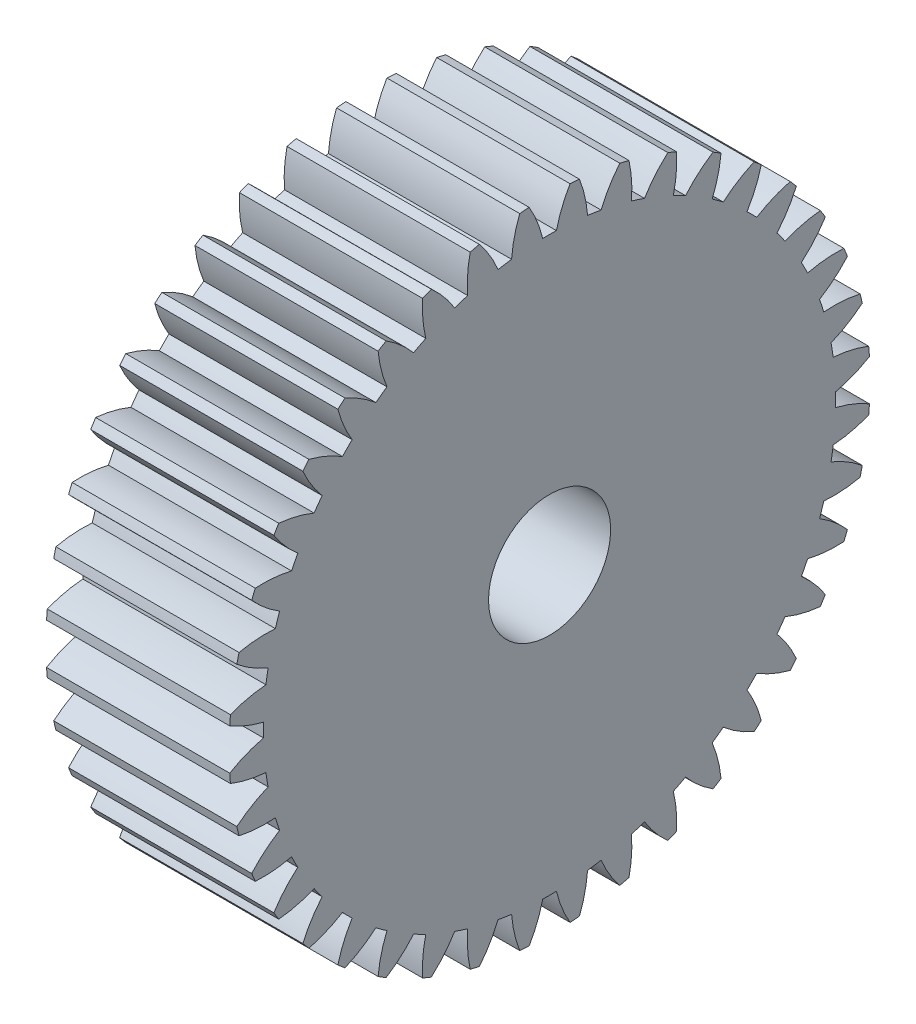
from build123d import *

# Parameters (mm, degrees)
BASPROSKE_W     = 12
BASPROSKE_H     = 21
TOOTHCUT_DEPTH  = 33.031234756
TEETHCUTS_COUNT = 40
TEETHCUTS_ANGLE = 351
BORSKE_R        = 4
BORE_DEPTH      = 50.0000508


with BuildPart() as part:
    # BasProSke → Base-Revolve (revolve)
    with BuildSketch(Plane(origin=(0, 0, 0), x_dir=(1, 0, 0), z_dir=(0, 1, 0)), mode=Mode.PRIVATE) as base_revolve_sk:
        with Locations((6, 10.5)):
            Rectangle(BASPROSKE_W, BASPROSKE_H)
    revolve(base_revolve_sk.sketch.rotate(Axis((-10, 0, 0), (1, 0, 0)), 180), axis=Axis((-10, 0, 0), (1, 0, 0)))

    # TooCutSke → ToothCut (cut, through all)
    with BuildSketch(Plane(origin=(0, 0, 0), x_dir=(0, 0, -1), z_dir=(1, 0, 0))):
        with BuildLine():
            ThreePointArc((0.448673268, 18.74363074), (0, 18.749), (-0.448673268, 18.74363074))
            ThreePointArc((-0.448673268, 18.74363074), (-0.816786816, 19.89705013), (-1.354745081, 20.981708961))
            ThreePointArc((-1.354745081, 20.981708961), (0, 21.0254), (1.354745081, 20.981708961))
            ThreePointArc((1.354745081, 20.981708961), (0.816786816, 19.89705013), (0.448673268, 18.74363074))
        make_face()
    toothcut = extrude(amount=TOOTHCUT_DEPTH, mode=Mode.SUBTRACT)

    # TeethCuts: ToothCut ×40 about axis
    teethcuts_axis = Axis((-10, 0, 0), (1, 0, 0))
    for i in range(1, TEETHCUTS_COUNT):
        add(toothcut.rotate(teethcuts_axis, i * TEETHCUTS_ANGLE / (TEETHCUTS_COUNT - 1)), mode=Mode.SUBTRACT)

    # BorSke → Bore (cut, symmetric)
    with BuildSketch(Plane(origin=(0, 0, 0), x_dir=(0, 0, -1), z_dir=(1, 0, 0))):
        with Locations(Location((0, 0, 0), (0, 0, 180))):
            Circle(BORSKE_R)
    extrude(amount=BORE_DEPTH, both=True, mode=Mode.SUBTRACT)


solid = part.part
